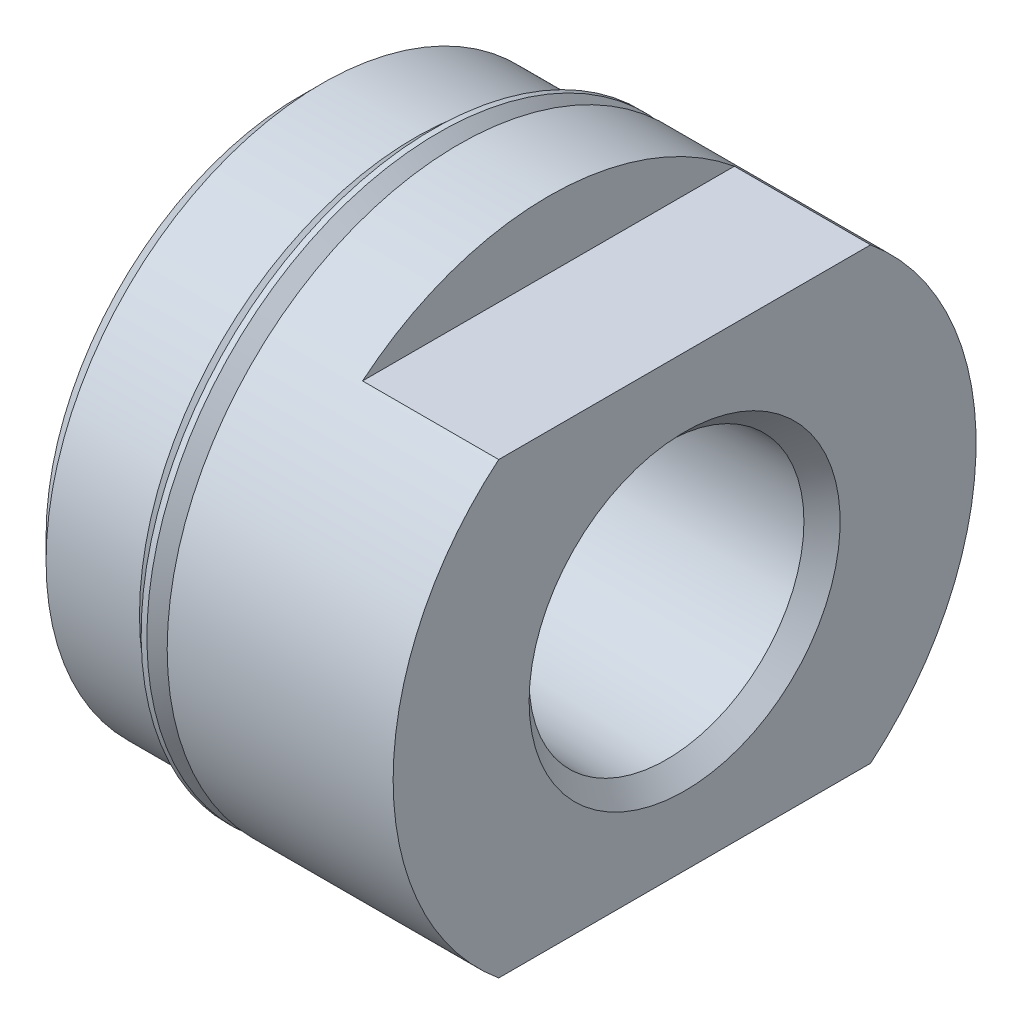
from build123d import *

# Parameters (mm, degrees)
SKETCH3_W          = 81.788
SKETCH3_H          = 40.894
SKETCH3_W_2        = 40.894
SKETCH3_H_2        = 15.748
CUT_EXTRUDE1_DEPTH = 4.7752


with BuildPart() as part:
    # Sketch1 → Revolve1 (revolve)
    with BuildSketch(Plane.XY):
        Polygon((0, 0), (0, 8.90905), (0.762, 9.67105), (4.0386, 9.67105), (4.8006, 8.90905), (5.5626, 8.90905), (5.5626, 10.2235), (13.4874, 10.2235), (13.4874, 0), align=None)
    revolve(axis=Axis((13.4874, 0, 0), (-1, 0, 0)))

    # Sketch2 → Cut-Revolve1 (revolve, cut)
    with BuildSketch(Plane.XY):
        Polygon((0, 0), (0, 4.3688), (-1.588923892, 4.3688), (12.852387191, 4.819651116), (13.4874, 5.454663925), (13.4874, 0), align=None)
    revolve(axis=Axis((13.4874, 0, 0), (-1, 0, 0)), mode=Mode.SUBTRACT)

    # Sketch3 → Cut-Extrude1 (cut)
    with BuildSketch(Plane(origin=(13.4874, 0, 0), x_dir=(0, 0, -1), z_dir=(1, 0, 0))):
        Rectangle(SKETCH3_W, SKETCH3_H)
        Rectangle(SKETCH3_W_2, SKETCH3_H_2, mode=Mode.SUBTRACT)
    extrude(amount=-CUT_EXTRUDE1_DEPTH, mode=Mode.SUBTRACT)

    # Sketch4 → Revolve2 (revolve)
    with BuildSketch(Plane.XY):
        with BuildLine():
            Line((4.64794893, 10.2235), (4.64794893, 10.139331804))
            Line((4.64794893, 10.139331804), (5.440112806, 9.347167928))
            ThreePointArc((5.440112806, 9.347167928), (5.477310245, 9.257365367), (5.440112806, 9.167562806))
            Line((5.440112806, 9.167562806), (5.1816, 8.90905))
            Line((5.1816, 8.90905), (4.8006, 8.90905))
            Line((4.8006, 8.90905), (4.8006, 8.65505))
            Line((4.8006, 8.65505), (5.5626, 8.65505))
            Line((5.5626, 8.65505), (5.5626, 9.51204893))
            Line((5.5626, 9.51204893), (4.85114893, 10.2235))
            Line((4.85114893, 10.2235), (4.64794893, 10.2235))
        make_face()
    revolve(axis=Axis((5.5626, 0, 0), (-1, 0, 0)))


solid = part.part
